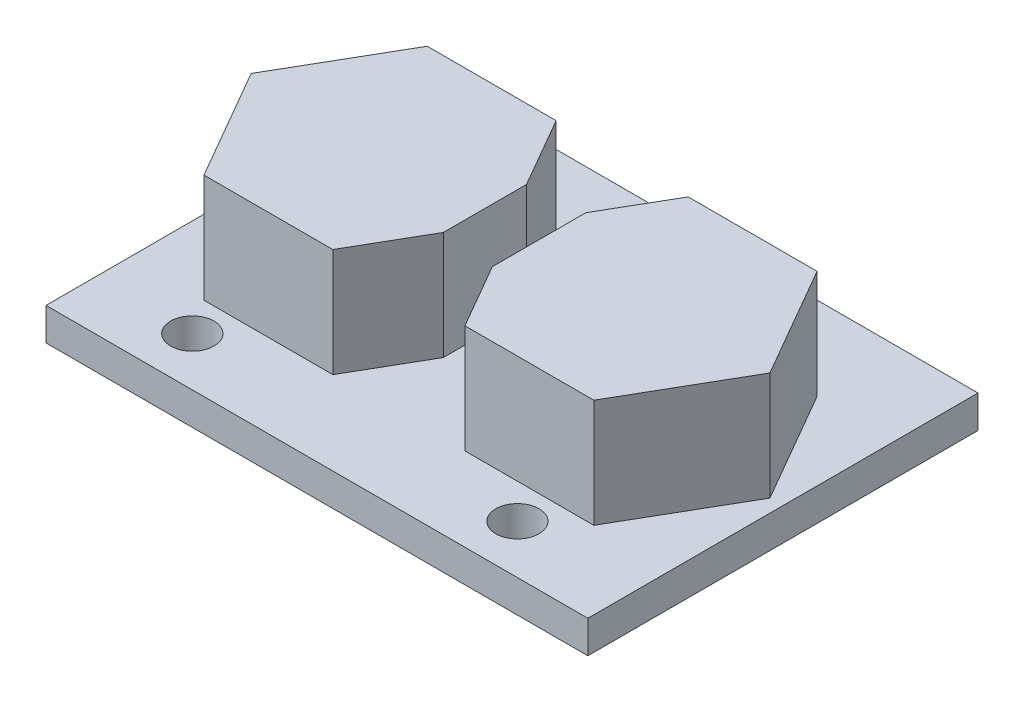
from build123d import *

# Parameters (mm, degrees)
SKETCH2_W           = 25
SKETCH2_H           = 18
BOSS_EXTRUDE1_DEPTH = 1.5
BOSS_EXTRUDE2_DEPTH = 5
SKETCH5_R           = 1
CUT_EXTRUDE1_DEPTH  = 1.5


with BuildPart() as part:
    # Sketch2 → Boss-Extrude1 (new body)
    with BuildSketch(Plane(origin=(0, 0, 0), x_dir=(1, 0, 0), z_dir=(0, 1, 0))):
        with Locations((12.5, 9)):
            Rectangle(SKETCH2_W, SKETCH2_H)
    extrude(amount=BOSS_EXTRUDE1_DEPTH)

    # Sketch3 → Boss-Extrude2 (add)
    with BuildSketch(Plane(origin=(0, 1.5, 0), x_dir=(1, 0, 0), z_dir=(0, 1, 0))):
        Polygon((3.438353886, 3.85), (9.385061659, 3.85), (11.25, 7.08016796), (11.25, 10.91983204), (9.385061659, 14.15), (3.438353886, 14.15), (0.465, 9), align=None)
        Polygon((13.75, 11.156403255), (13.75, 6.843596745), (15.478353886, 3.85), (21.425061659, 3.85), (24.398415545, 9), (21.425061659, 14.15), (15.478353886, 14.15), align=None)
    extrude(amount=BOSS_EXTRUDE2_DEPTH)

    # Sketch5 → Cut-Extrude1 (cut)
    with BuildSketch(Plane.XZ):
        with Locations((4.5, -2.25)):
            Circle(SKETCH5_R)
        with Locations((19.5, -2.25)):
            Circle(SKETCH5_R)
    extrude(amount=-CUT_EXTRUDE1_DEPTH, mode=Mode.SUBTRACT)


solid = part.part
